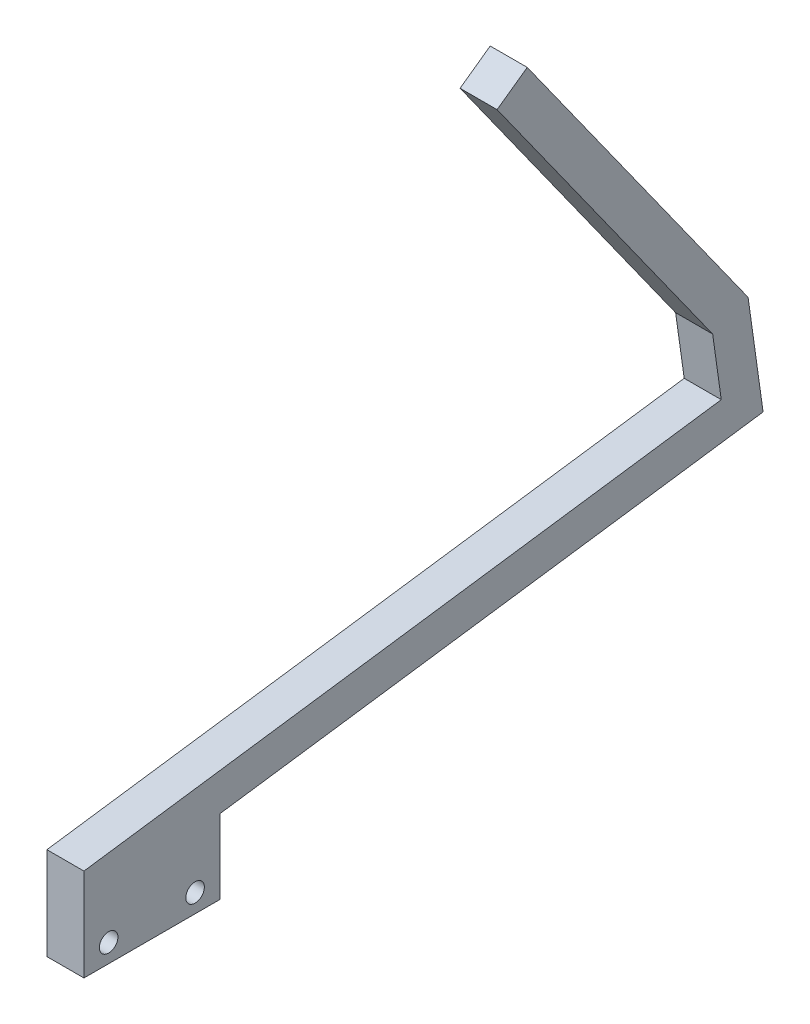
from build123d import *

# Parameters (mm, degrees)
SKETCH1_R           = 1.5
BOSS_EXTRUDE1_DEPTH = 6


with BuildPart() as part:
    # Sketch1 → Boss-Extrude1 (new body)
    with BuildSketch(Plane(origin=(0, 0, 0), x_dir=(0, 0, -1), z_dir=(1, 0, 0))):
        Polygon((0, 0), (0, 15), (103.223352982, 29.507096189), (101.831621972, 39.409776876), (66.916528588, 88.345571837), (71.800771975, 91.830419975), (107.568840624, 41.699124196), (110, 24.400526382), (22, 12.032932928), (22, 0), align=None)
        with Locations((4, 3)):
            Circle(SKETCH1_R, mode=Mode.SUBTRACT)
        with Locations((18, 3)):
            Circle(SKETCH1_R, mode=Mode.SUBTRACT)
    extrude(amount=BOSS_EXTRUDE1_DEPTH)


solid = part.part
